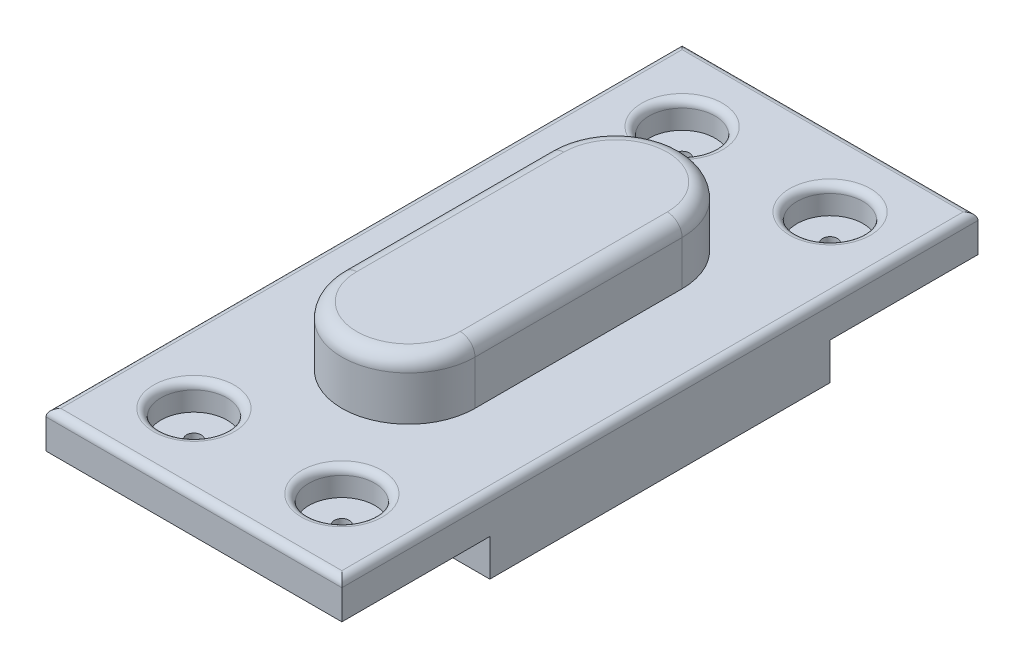
from build123d import *

# Parameters (mm, degrees)
BOSS_EXTRUDE1_DEPTH = 4
BOSS_EXTRUDE2_DEPTH = 5
SKETCH6_W           = 10
SKETCH6_H           = 2.5
CUT_EXTRUDE5_DEPTH  = 20
SKETCH7_R           = 2.231522852
SKETCH7_R_2         = 0.5
CUT_EXTRUDE6_DEPTH  = 1.8
SKETCH7_2_R         = 0.5
CUT_EXTRUDE7_DEPTH  = 2.5
FILLET1_R           = 0.5
FILLET2_R           = 1
SKETCH9_W           = 17.5
SKETCH9_H           = 11
CUT_EXTRUDE8_DEPTH  = 4
SKETCH9_3_R         = 0.5
CUT_EXTRUDE9_DEPTH  = 8


with BuildPart() as part:
    # Sketch1 → Boss-Extrude1 (new body)
    with BuildSketch(Plane(origin=(0, 0, 0), x_dir=(1, 0, 0), z_dir=(0, 1, 0))):
        with BuildLine():
            Line((78.5, 7), (78.5, -7))
            ThreePointArc((78.5, -7), (83, -11.5), (87.5, -7))
            Line((87.5, -7), (87.5, 7))
            ThreePointArc((87.5, 7), (83, 11.5), (78.5, 7))
        make_face()
    extrude(amount=BOSS_EXTRUDE1_DEPTH)

    # Fillet2
    fillet2_edges = [part.edges().sort_by_distance(p)[0] for p in [
        (78.5, 4, 0),
        (83, 4, 11.5),
        (87.5, 4, 0),
        (83, 4, -11.5),
    ]]
    fillet(fillet2_edges, radius=FILLET2_R)


with BuildPart() as body_2:
    # Sketch1_3 → Boss-Extrude2 (new body)
    with BuildSketch(Plane(origin=(0, 0, 0), x_dir=(1, 0, 0), z_dir=(0, 1, 0))):
        with BuildLine():
            Line((78.5, -7), (78.5, 0))
            Line((78.5, 0), (73, 0))
            Line((73, 0), (73, -21.5))
            Line((73, -21.5), (93, -21.5))
            Line((93, -21.5), (93, 0))
            Line((93, 0), (87.5, 0))
            Line((87.5, 0), (87.5, -7))
            ThreePointArc((87.5, -7), (83, -11.5), (78.5, -7))
        make_face()
        with BuildLine():
            Line((78.5, 0), (78.5, 7))
            ThreePointArc((78.5, 7), (83, 11.5), (87.5, 7))
            Line((87.5, 7), (87.5, 0))
            Line((87.5, 0), (93, 0))
            Line((93, 0), (93, 21.5))
            Line((93, 21.5), (73, 21.5))
            Line((73, 21.5), (73, 0))
            Line((73, 0), (78.5, 0))
        make_face()
        with BuildLine():
            Line((87.5, 0), (78.5, 0))
            Line((78.5, 0), (78.5, -7))
            ThreePointArc((78.5, -7), (83, -11.5), (87.5, -7))
            Line((87.5, -7), (87.5, 0))
        make_face()
        with BuildLine():
            ThreePointArc((87.5, 7), (83, 11.5), (78.5, 7))
            Line((78.5, 7), (78.5, 0))
            Line((78.5, 0), (87.5, 0))
            Line((87.5, 0), (87.5, 7))
        make_face()
    extrude(amount=-BOSS_EXTRUDE2_DEPTH)

    # Sketch6 → Cut-Extrude5 (cut)
    with BuildSketch(Plane(origin=(93, 0, 0), x_dir=(0, 0, -1), z_dir=(1, 0, 0))):
        with Locations((16.5, -3.75)):
            Rectangle(SKETCH6_W, SKETCH6_H)
        with Locations((-16.5, -3.75)):
            Rectangle(SKETCH6_W, SKETCH6_H)
    extrude(amount=-CUT_EXTRUDE5_DEPTH, mode=Mode.SUBTRACT)

    # Sketch7 → Cut-Extrude6 (cut)
    with BuildSketch(Plane(origin=(0, 0, 0), x_dir=(1, 0, 0), z_dir=(0, 1, 0))):
        with Locations((78, 16.5)):
            Circle(SKETCH7_R)
        with Locations((78, 16.5)):
            Circle(SKETCH7_R_2, mode=Mode.SUBTRACT)
        with Locations((88, 16.5)):
            Circle(SKETCH7_R)
        with Locations((88, 16.5)):
            Circle(SKETCH7_R_2, mode=Mode.SUBTRACT)
        with Locations((88, -16.5)):
            Circle(SKETCH7_R)
        with Locations((88, -16.5)):
            Circle(SKETCH7_R_2, mode=Mode.SUBTRACT)
        with Locations((78, -16.5)):
            Circle(SKETCH7_R)
        with Locations((78, -16.5)):
            Circle(SKETCH7_R_2, mode=Mode.SUBTRACT)
    extrude(amount=-CUT_EXTRUDE6_DEPTH, mode=Mode.SUBTRACT)

    # Sketch7_2 → Cut-Extrude7 (cut)
    with BuildSketch(Plane(origin=(0, 0, 0), x_dir=(1, 0, 0), z_dir=(0, 1, 0))):
        with Locations((88, 16.5)):
            Circle(SKETCH7_2_R)
        with Locations((78, -16.5)):
            Circle(SKETCH7_2_R)
        with Locations((88, -16.5)):
            Circle(SKETCH7_2_R)
        with Locations((78, 16.5)):
            Circle(SKETCH7_2_R)
    extrude(amount=-CUT_EXTRUDE7_DEPTH, mode=Mode.SUBTRACT)

    # Fillet1
    fillet1_edges = [body_2.edges().sort_by_distance(p)[0] for p in [
        (75.768477148, 0, 16.5),
        (85.768477148, 0, 16.5),
        (85.768477148, 0, -16.5),
        (75.768477148, 0, -16.5),
        (93, 0, 0),
        (83, 0, 21.5),
        (73, 0, 0),
        (83, 0, -21.5),
    ]]
    fillet(fillet1_edges, radius=FILLET1_R)

    # Sketch9 → Cut-Extrude8 (cut)
    with BuildSketch(Plane.XZ.offset(5)):
        with Locations((81.75, 0)):
            Rectangle(SKETCH9_W, SKETCH9_H)
    extrude(amount=-CUT_EXTRUDE8_DEPTH, mode=Mode.SUBTRACT)


with BuildPart() as cut_extrude9_tool:
    # Sketch9_3 → Cut-Extrude9 (new body)
    with BuildSketch(Plane.XZ.offset(5)):
        with Locations((83, -2.75)):
            Circle(SKETCH9_3_R)
        with Locations((83, 2.75)):
            Circle(SKETCH9_3_R)
    extrude(amount=-CUT_EXTRUDE9_DEPTH)


with BuildPart() as part_1:
    add(part.part)

    # Cut-Extrude9: cut by cut_extrude9_tool
    add(cut_extrude9_tool.part, mode=Mode.SUBTRACT)


with BuildPart() as body_2_1:
    add(body_2.part)

    # Cut-Extrude9: cut by cut_extrude9_tool
    add(cut_extrude9_tool.part, mode=Mode.SUBTRACT)


solid = Compound([part_1.part, body_2_1.part])
